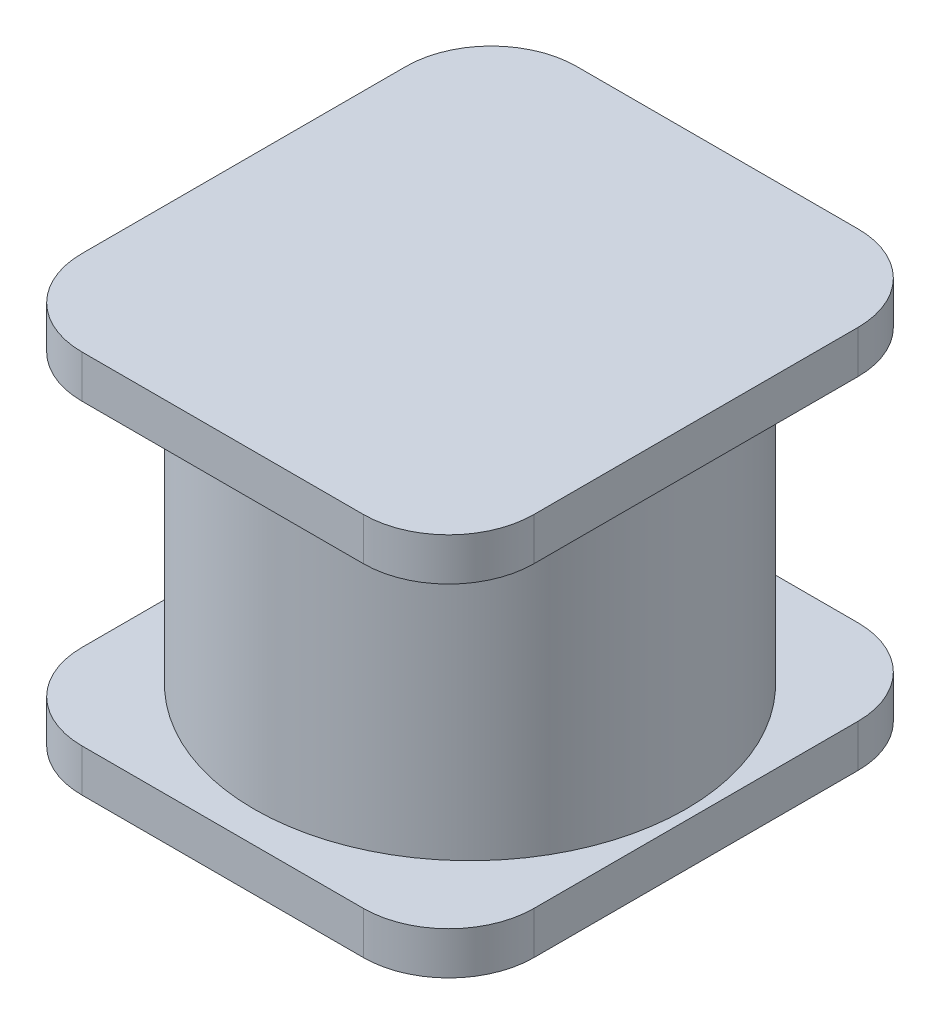
from build123d import *

# Parameters (mm, degrees)
SKETCH1_W           = 5.3
SKETCH1_H           = 5.8
BOSS_EXTRUDE1_DEPTH = 0.5
SKETCH2_R           = 2.533399168
BOSS_EXTRUDE2_DEPTH = 3.5
SKETCH3_W           = 5.3
SKETCH3_H           = 5.8
BOSS_EXTRUDE3_DEPTH = 0.5
FILLET1_R           = 1


with BuildPart() as part:
    # Sketch1 → Boss-Extrude1 (new body)
    with BuildSketch(Plane(origin=(0, 0, 0), x_dir=(1, 0, 0), z_dir=(0, 1, 0))):
        Rectangle(SKETCH1_W, SKETCH1_H)
    extrude(amount=BOSS_EXTRUDE1_DEPTH)

    # Sketch2 → Boss-Extrude2 (add)
    with BuildSketch(Plane(origin=(0, 0.5, 0), x_dir=(-1, 0, 0), z_dir=(0, 1, 0))):
        Circle(SKETCH2_R)
    extrude(amount=BOSS_EXTRUDE2_DEPTH)

    # Sketch3 → Boss-Extrude3 (add)
    with BuildSketch(Plane(origin=(0, 4, 0), x_dir=(-1, 0, 0), z_dir=(0, 1, 0))):
        Rectangle(SKETCH3_W, SKETCH3_H)
    extrude(amount=BOSS_EXTRUDE3_DEPTH)

    # Fillet1
    fillet1_edges = [part.edges().sort_by_distance(p)[0] for p in [
        (-2.65, 4.25, -2.9),
        (-2.65, 4.25, 2.9),
        (2.65, 4.25, 2.9),
        (2.65, 4.25, -2.9),
        (2.65, 0.25, 2.9),
        (-2.65, 0.25, 2.9),
        (-2.65, 0.25, -2.9),
        (2.65, 0.25, -2.9),
    ]]
    fillet(fillet1_edges, radius=FILLET1_R)


solid = part.part
